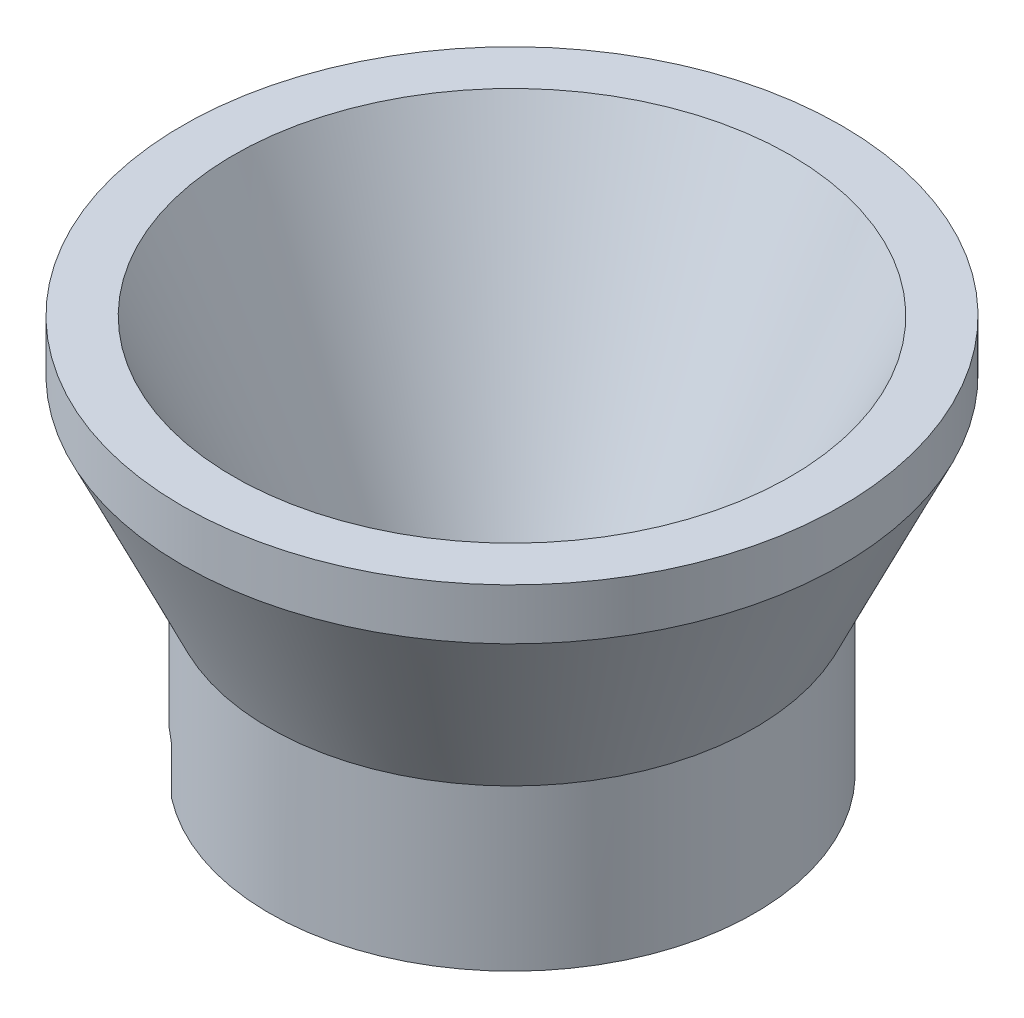
from build123d import *

# Parameters (mm, degrees)
CUT_EXTRUDE1_REACH = 14.9
SKETCH2_W          = 15
SKETCH2_H          = 1.85


with BuildPart() as part:
    # Sketch1 → Revolve1 (revolve)
    with BuildSketch(Plane(origin=(0, 0, 0), x_dir=(0, 0, -1), z_dir=(1, 0, 0))):
        Polygon((-7.5, 0), (-7.5, 1.85), (-5.85, 3.5), (-5.25, 3.5), (-10.9, 15.5), (-12.9, 15.5), (-12.9, 13.5), (-9.5, 6.278761062), (-9.5, 0), align=None)
    revolve(axis=Axis((0, 0, 0), (0, 1, 0)))

    # Sketch2 → Cut-Extrude1 (cut, up to next)
    with BuildSketch(Plane(origin=(0, 0, 0), x_dir=(0, 0, -1), z_dir=(1, 0, 0)), mode=Mode.PRIVATE) as cut_extrude1_sk1:
        with Locations((0, 0.925)):
            Rectangle(SKETCH2_W, SKETCH2_H)
    cut_extrude1_tool1 = extrude(cut_extrude1_sk1.sketch, amount=-CUT_EXTRUDE1_REACH, mode=Mode.PRIVATE) & part.part
    add(cut_extrude1_tool1.solids().sort_by_distance((0, 0.925, 0))[0], mode=Mode.SUBTRACT)


solid = part.part
